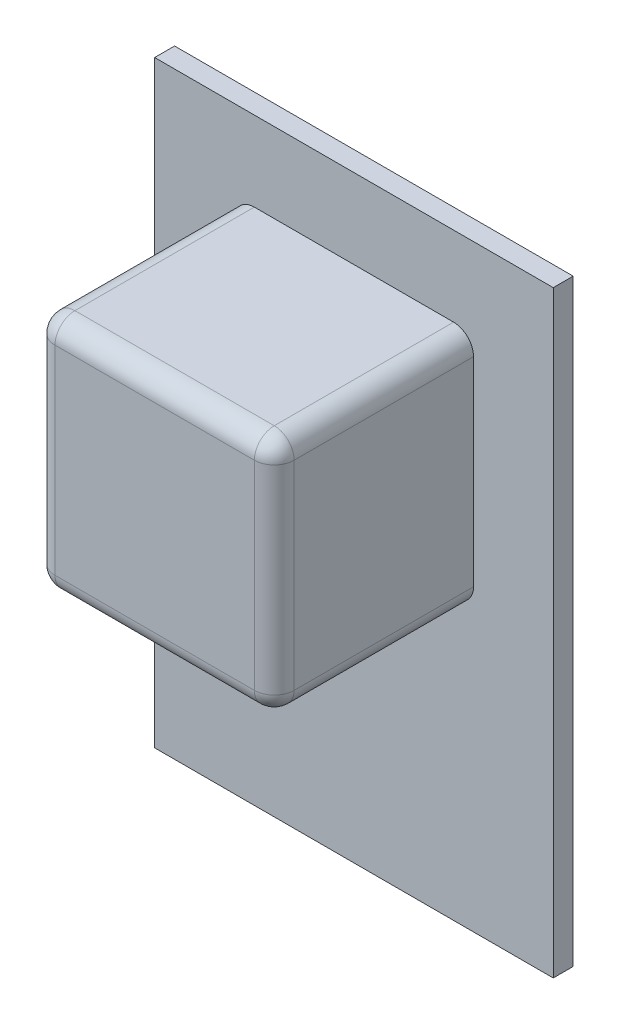
from build123d import *

# Parameters (mm, degrees)
SKETCH_1_W      = 200
SKETCH_1_H      = 300
EXTRUDE_1_DEPTH = 10
SKETCH_2_W      = 120
SKETCH_2_H      = 120
EXTRUDE_2_DEPTH = 100
FILLET_1_R      = 10


with BuildPart() as part:
    # 草图1 → 凸台-拉伸1 (new body)
    with BuildSketch(Plane.XY):
        Rectangle(SKETCH_1_W, SKETCH_1_H)
    extrude(amount=-EXTRUDE_1_DEPTH)

    # 草图2 → 凸台-拉伸2 (add)
    with BuildSketch(Plane.XY):
        with Locations((0, 50)):
            Rectangle(SKETCH_2_W, SKETCH_2_H)
    extrude(amount=EXTRUDE_2_DEPTH)

    # 圆角1
    fillet_1_edges = [part.edges().sort_by_distance(p)[0] for p in [
        (60, -10, 50),
        (60, 110, 50),
        (-60, 110, 50),
        (-60, -10, 50),
        (60, 50, 100),
        (0, 110, 100),
        (-60, 50, 100),
        (0, -10, 100),
    ]]
    fillet(fillet_1_edges, radius=FILLET_1_R)


solid = part.part
